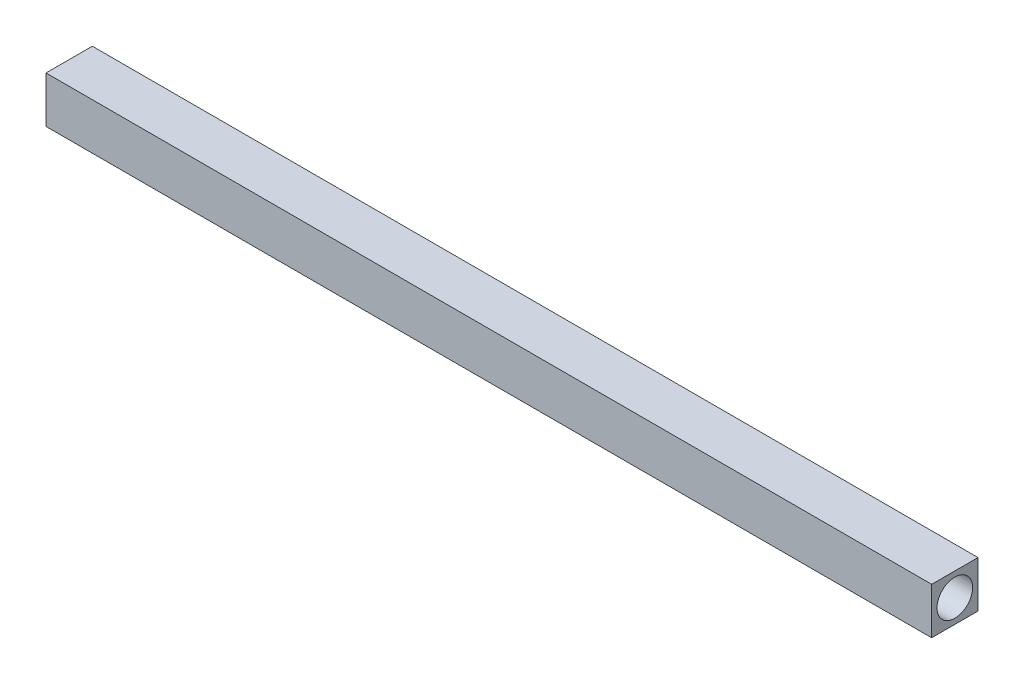
from build123d import *

# Parameters (mm, degrees)
SKETCH1_W           = 3.302
SKETCH1_H           = 3.302
BOSS_EXTRUDE1_DEPTH = 31.5595
SKETCH2_R           = 1.27
CUT_EXTRUDE1_DEPTH  = 3.175


with BuildPart() as part:
    # Sketch1 → Boss-Extrude1 (new body, symmetric)
    with BuildSketch(Plane(origin=(0, 0, 0), x_dir=(0, 0, -1), z_dir=(1, 0, 0))):
        Rectangle(SKETCH1_W, SKETCH1_H)
    extrude(amount=BOSS_EXTRUDE1_DEPTH, both=True)

    # Sketch2 → Cut-Extrude1 (cut)
    with BuildSketch(Plane(origin=(31.5595, 0, 0), x_dir=(0, 0, -1), z_dir=(1, 0, 0))):
        Circle(SKETCH2_R)
    cut_extrude1 = extrude(amount=-CUT_EXTRUDE1_DEPTH, mode=Mode.SUBTRACT)

    # Mirror1: Cut-Extrude1 across plane
    add(cut_extrude1.mirror(Plane(origin=(0, 0, 0), x_dir=(0, 0, 1), z_dir=(1, 0, 0))), mode=Mode.SUBTRACT)


solid = part.part
